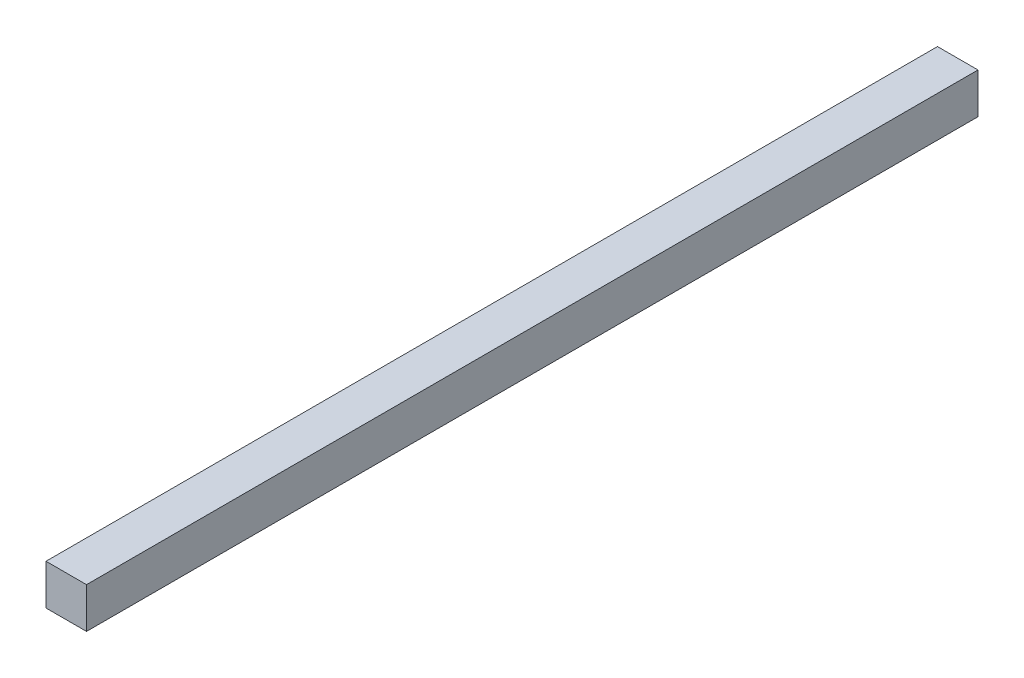
from build123d import *

# Parameters (mm, degrees)
SKETCH4_W           = 25.4
SKETCH4_H           = 25.4
BOSS_EXTRUDE2_DEPTH = 558.8


with BuildPart() as part:
    # Sketch4 → Boss-Extrude2 (new body)
    with BuildSketch(Plane.XY):
        Rectangle(SKETCH4_W, SKETCH4_H)
    extrude(amount=BOSS_EXTRUDE2_DEPTH)


solid = part.part
